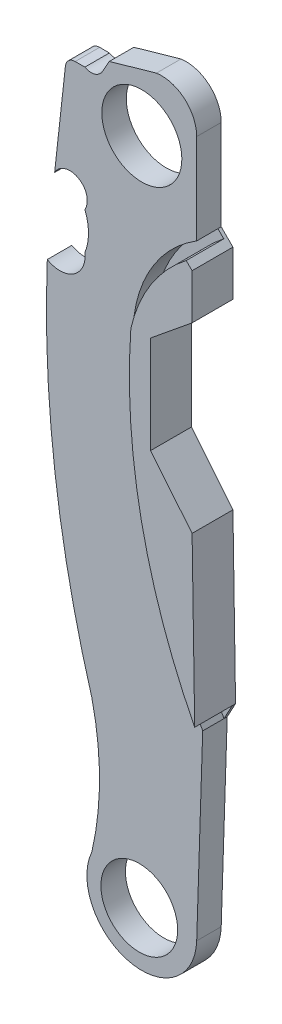
from build123d import *

# Parameters (mm, degrees)
SKETCH1_R           = 3.1115
SKETCH1_R_2         = 2.9845
BOSS_EXTRUDE1_DEPTH = 1.905
CUT_EXTRUDE1_DEPTH  = 1.651
BOSS_EXTRUDE2_DEPTH = 1.27
FILLET4_R           = 0.762


with BuildPart() as part:
    # Sketch1 → Boss-Extrude1 (new body)
    with BuildSketch(Plane.XY):
        with BuildLine():
            Line((61.17139063, 26.332220791), (60.704944856, 11.966179777))
            ThreePointArc((60.704944856, 11.966179777), (55.469656343, 7.945478091), (52.551985386, 13.866751944))
            ThreePointArc((52.551985386, 13.866751944), (53.150243594, 19.068304512), (52.551985386, 24.269857079))
            ThreePointArc((52.551985386, 24.269857079), (49.685224569, 38.006015424), (49.090889591, 52.025542148))
            ThreePointArc((49.090889591, 52.025542148), (51.146965053, 52.083276575), (52.012792223, 53.949053326))
            ThreePointArc((52.012792223, 53.949053326), (52.29374244, 55.401070195), (52.012792223, 56.853087065))
            ThreePointArc((52.012792223, 56.853087065), (51.509420049, 58.711680371), (49.661768019, 58.169523016))
            Line((49.661768019, 58.169523016), (50.574786632, 66.4382933))
            Line((50.574786632, 66.4382933), (52.012792223, 66.4382933))
            ThreePointArc((52.012792223, 66.4382933), (52.772258586, 66.349188863), (53.373853233, 66.821219197))
            Line((53.373853233, 66.821219197), (53.909482304, 67.76887063))
            Line((53.909482304, 67.76887063), (57.57460461, 68.813123354))
            ThreePointArc((57.57460461, 68.813123354), (59.75855859, 68.176663617), (60.704944856, 66.10806771))
            Line((60.704944856, 66.10806771), (60.704944856, 59.081610081))
            Line((60.704944856, 59.081610081), (61.617031921, 58.169523016))
            Line((61.617031921, 58.169523016), (61.617031921, 54.655997897))
            Line((61.617031921, 54.655997897), (58.390036251, 52.025542148))
            Line((58.390036251, 52.025542148), (58.390036251, 44.445572853))
            Line((58.390036251, 44.445572853), (61.617031921, 40.486752766))
            Line((61.617031921, 40.486752766), (61.819220674, 27.533280913))
            Line((61.819220674, 27.533280913), (61.17139063, 26.332220791))
        make_face()
        with Locations((56.438703811, 64.020773394)):
            Circle(SKETCH1_R, mode=Mode.SUBTRACT)
        with Locations((56.241951704, 11.95715462)):
            Circle(SKETCH1_R_2, mode=Mode.SUBTRACT)
    extrude(amount=BOSS_EXTRUDE1_DEPTH)

    # Sketch2 → Cut-Extrude1 (cut)
    with BuildSketch(Plane.XY.offset(1.905)):
        with BuildLine():
            Line((60.704944856, 59.081610081), (61.160988389, 58.625566549))
            ThreePointArc((61.160988389, 58.625566549), (58.418398779, 55.641187467), (56.855649817, 51.901383735))
            ThreePointArc((56.855649817, 51.901383735), (57.672831025, 39.378266905), (61.819220674, 27.533280913))
            Line((61.819220674, 27.533280913), (61.17139063, 26.332220791))
            ThreePointArc((61.17139063, 26.332220791), (56.696533643, 38.574284868), (55.8334865, 51.57996161))
            ThreePointArc((55.8334865, 51.57996161), (57.423428617, 55.880027317), (60.704944856, 59.081610081))
        make_face()
    extrude(amount=-CUT_EXTRUDE1_DEPTH, mode=Mode.SUBTRACT)

    # Sketch3 → Boss-Extrude2 (add)
    with BuildSketch(Plane.XY.offset(1.905)):
        with BuildLine():
            Line((61.819220674, 27.533280913), (61.617031921, 40.486752766))
            Line((61.617031921, 40.486752766), (58.390036251, 44.445572853))
            Line((58.390036251, 44.445572853), (58.390036251, 52.025542148))
            Line((58.390036251, 52.025542148), (61.617031921, 54.655997897))
            Line((61.617031921, 54.655997897), (61.617031921, 58.169523016))
            Line((61.617031921, 58.169523016), (61.160988389, 58.625566549))
            ThreePointArc((61.160988389, 58.625566549), (58.418398779, 55.641187467), (56.855649817, 51.901383735))
            ThreePointArc((56.855649817, 51.901383735), (57.672831025, 39.378266905), (61.819220674, 27.533280913))
        make_face()
    extrude(amount=BOSS_EXTRUDE2_DEPTH)

    # Fillet4
    fillet4_edges = [part.edges().sort_by_distance(p)[0] for p in [
        (50.574786632, 66.4382933, 0.9525),
    ]]
    fillet(fillet4_edges, radius=FILLET4_R)


solid = part.part
